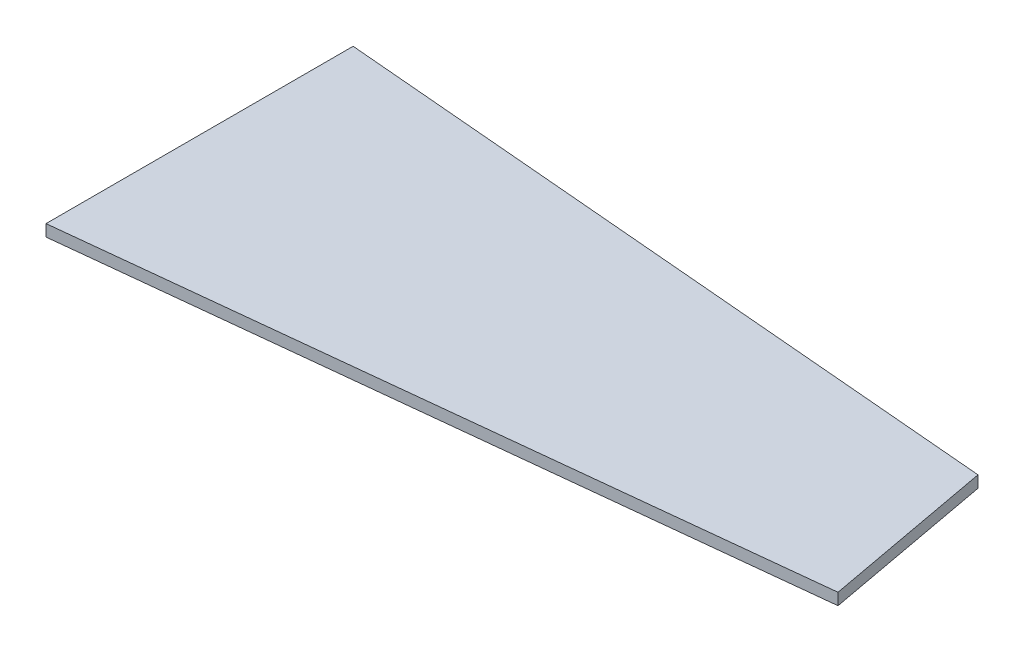
from build123d import *

# Parameters (mm, degrees)
BOSS_EXTRU_1_DEPTH = 2


with BuildPart() as part:
    # Esquisse1 → Boss.-Extru.1 (new body)
    with BuildSketch(Plane(origin=(0, 0, 0), x_dir=(1, 0, 0), z_dir=(0, 1, 0))):
        Polygon((117.105263204, 42.564022224), (0, 52.618992939), (0, 0), (122.540188295, 13.147125987), align=None)
    extrude(amount=BOSS_EXTRU_1_DEPTH)


solid = part.part
